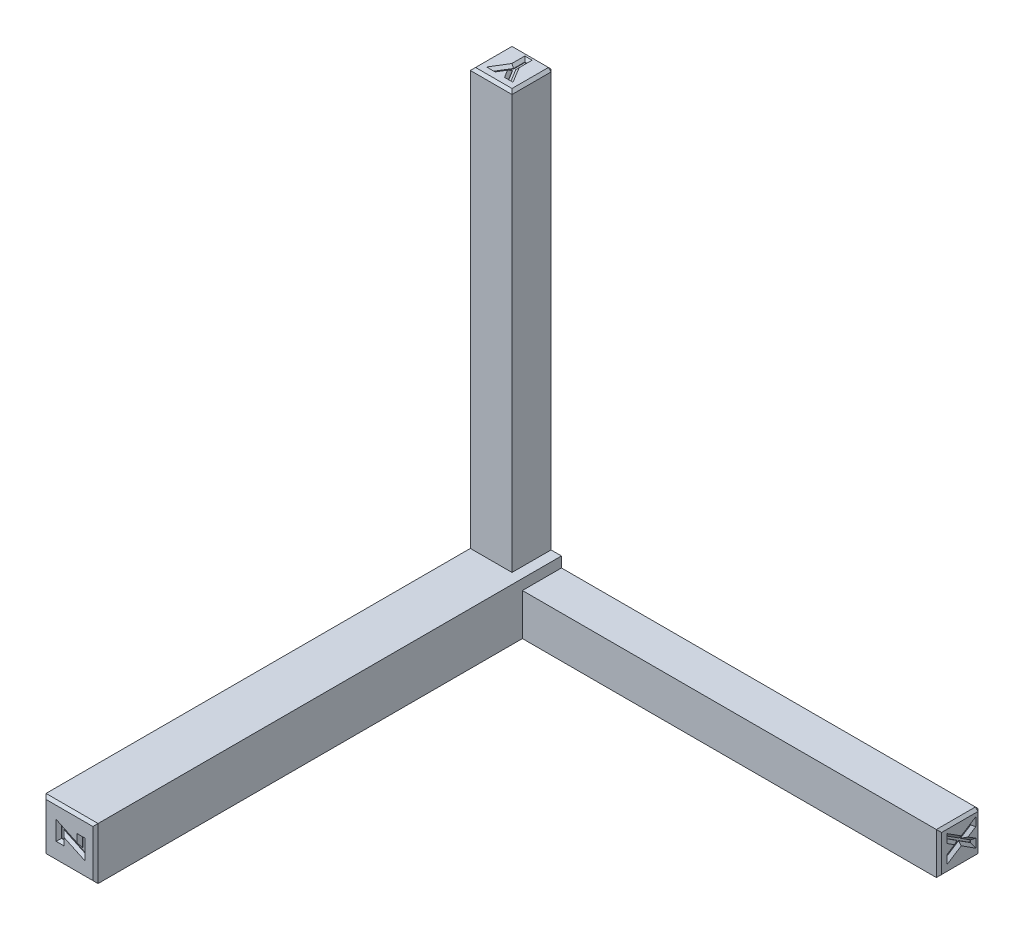
from build123d import *

# Parameters (mm, degrees)
SKETCH1_W           = 10
SKETCH1_H           = 10
BOSS_EXTRUDE1_DEPTH = 90
SKETCH2_W           = 8
SKETCH2_H           = 8
BOSS_EXTRUDE2_DEPTH = 80
SKETCH3_W           = 8
SKETCH3_H           = 8
BOSS_EXTRUDE3_DEPTH = 80
CUT_EXTRUDE1_DEPTH  = 0.6
CUT_EXTRUDE2_DEPTH  = 0.6
CUT_EXTRUDE3_DEPTH  = 0.6
CHAMFER1_SIZE       = 0.5


with BuildPart() as part:
    # Sketch1 → Boss-Extrude1 (new body)
    with BuildSketch(Plane.XY):
        with Locations((5, 5)):
            Rectangle(SKETCH1_W, SKETCH1_H)
    extrude(amount=BOSS_EXTRUDE1_DEPTH)

    # Sketch2 → Boss-Extrude2 (add)
    with BuildSketch(Plane(origin=(10, 0, 0), x_dir=(0, 0, -1), z_dir=(1, 0, 0))):
        with Locations((-4, 4)):
            Rectangle(SKETCH2_W, SKETCH2_H)
    extrude(amount=BOSS_EXTRUDE2_DEPTH)

    # Sketch3 → Boss-Extrude3 (add)
    with BuildSketch(Plane(origin=(0, 10, 0), x_dir=(1, 0, 0), z_dir=(0, 1, 0))):
        with Locations((4, -4)):
            Rectangle(SKETCH3_W, SKETCH3_H)
    extrude(amount=BOSS_EXTRUDE3_DEPTH)

    # Sketch6 → Cut-Extrude1 (cut)
    with BuildSketch(Plane(origin=(90, 0, 0), x_dir=(0, 0, -1), z_dir=(1, 0, 0))):
        Polygon((-5.923065511, 5.863746423), (-5.923065511, 5.39770075), (-4.082320318, 4.219515654), (-5.923065511, 3.041330558), (-5.923065511, 2.575284885), (-3.718137626, 3.986042096), (-1.423065511, 2.517592577), (-1.423065511, 2.98363825), (-3.353954934, 4.219515654), (-1.423065511, 5.455393058), (-1.423065511, 5.921438731), (-3.718137626, 4.452087769), align=None)
    extrude(amount=-CUT_EXTRUDE1_DEPTH, mode=Mode.SUBTRACT)

    # Sketch7 → Cut-Extrude2 (cut)
    with BuildSketch(Plane(origin=(0, 90, 0), x_dir=(0, 0, -1), z_dir=(0, 1, 0))):
        Polygon((-5.865477289, -5.670481901), (-5.865477289, -5.208041997), (-3.931883539, -4.025349689), (-5.865477289, -2.844460266), (-5.865477289, -2.382020363), (-3.504599885, -3.824328055), (-1.365477289, -3.824328055), (-1.365477289, -4.228174209), (-3.504599885, -4.228174209), align=None)
    extrude(amount=-CUT_EXTRUDE2_DEPTH, mode=Mode.SUBTRACT)

    # Sketch8 → Cut-Extrude3 (cut)
    with BuildSketch(Plane.XY.offset(90)):
        Polygon((3.422101108, 3.999142166), (2.960562647, 3.999142166), (2.960562647, 6.364526781), (6.999024185, 4.476906589), (6.999024185, 6.306834473), (7.460562647, 6.306834473), (7.460562647, 3.826065243), (3.422101108, 5.713685435), align=None)
    extrude(amount=-CUT_EXTRUDE3_DEPTH, mode=Mode.SUBTRACT)

    # Chamfer1
    chamfer1_edges = [part.edges().sort_by_distance(p)[0] for p in [
        (5.441331878, 4.769875339, 90),
        (7.460562647, 5.066449858, 90),
        (7.229793416, 6.306834473, 90),
        (6.999024185, 5.391870531, 90),
        (4.979793416, 5.420716685, 90),
        (2.960562647, 5.181834473, 90),
        (3.191331878, 3.999142166, 90),
        (3.422101108, 4.8564138, 90),
        (5, 10, 90),
        (10, 5, 90),
        (5, 0, 90),
        (0, 5, 90),
        (4.026251132, 90, 1.365477289),
        (3.824328055, 90, 2.435038587),
        (3.103174209, 90, 4.685038587),
        (2.613240314, 90, 5.865477289),
        (3.434904978, 90, 4.898680414),
        (4.616695843, 90, 4.898680414),
        (5.439261949, 90, 5.865477289),
        (4.949328055, 90, 4.685038587),
        (4.228174209, 90, 2.435038587),
        (90, 5.630723587, 5.923065511),
        (90, 4.808608202, 5.002692915),
        (90, 3.630423106, 5.002692915),
        (90, 2.808307721, 5.923065511),
        (90, 3.28066349, 4.820601568),
        (90, 3.251817337, 2.570601568),
        (90, 2.750615413, 1.423065511),
        (90, 3.601576952, 2.388510222),
        (90, 4.837454356, 2.388510222),
        (90, 5.688415894, 1.423065511),
        (90, 5.18676325, 2.570601568),
        (90, 5.157917096, 4.820601568),
        (8, 90, 4),
        (4, 90, 8),
        (0, 90, 4),
        (90, 4, 8),
        (90, 8, 4),
        (90, 0, 4),
        (45, 0, 0),
        (90, 4, 0),
        (50, 8, 0),
        (10, 9, 0),
        (9, 10, 0),
        (8, 50, 0),
        (4, 90, 0),
        (0, 45, 0),
    ]]
    chamfer(chamfer1_edges, length=CHAMFER1_SIZE)


solid = part.part
